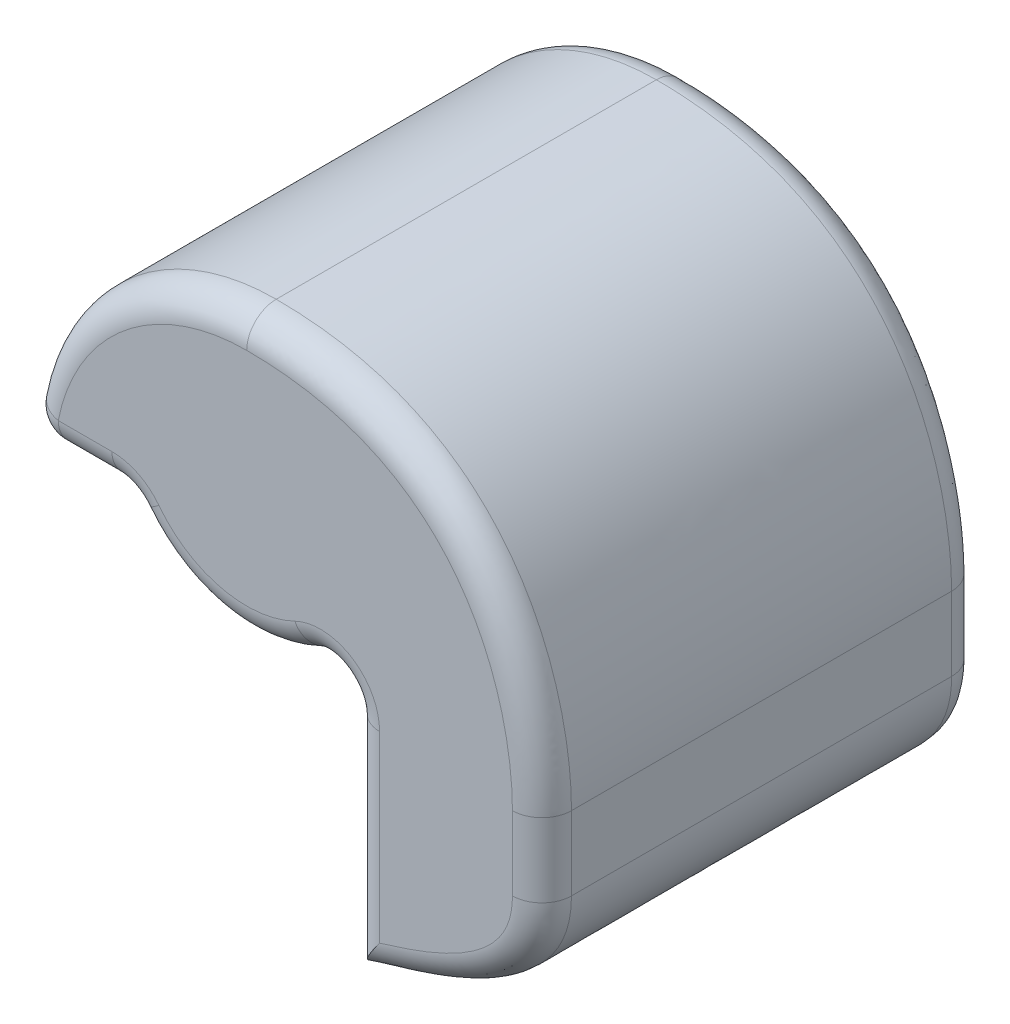
from build123d import *

# Parameters (mm, degrees)
SKETCH1_R            = 2
BOSS_EXTRUDE1_DEPTH  = 8.25
FILLET1_R            = 2
SKETCH1_3_R          = 2
BOSS_EXTRUDE2_DEPTH  = 13.25
FILLET1_OF_MIRROR1_R = 2
BOSS_EXTRUDE3_DEPTH  = 13.25
FILLET5_R            = 4
FILLET6_R            = 2


with BuildPart() as part:
    # Sketch1 → Boss-Extrude1 (new body)
    with BuildSketch(Plane.XY):
        with BuildLine():
            Line((7, -15.5), (7, -25.5))
            add(Edge.make_bspline(
                [(7, -25.5), (10.542331325, -24.196544486), (20, -22.646886742), (20, -15.5)],
                knots=[0, 0, 0, 0, 1, 1, 1, 1], degree=3))
            Line((20, -15.5), (20, -10.5))
            add(Edge.make_bspline(
                [(20, -10.5), (20, -3.471131344), (16.29951196, 9.5), (0, 9.5)],
                knots=[0, 0, 0, 0, 1, 1, 1, 1], degree=3))
            ThreePointArc((0, 9.5), (-10.431323023, 5.282403127), (-15, -5))
            Line((-15, -5), (-8.077747211, -5))
            ThreePointArc((-8.077747211, -5), (-0.892381106, -9.457994288), (7, -6.422616289))
            Line((7, -6.422616289), (7, -15.5))
        make_face()
        Circle(SKETCH1_R, mode=Mode.SUBTRACT)
        Circle(SKETCH1_R)
    boss_extrude1 = extrude(amount=BOSS_EXTRUDE1_DEPTH)

    # Fillet1
    fillet1_edges = [part.edges().sort_by_distance(p)[0] for p in [
        (7, -6.422616289, 4.125),
        (-8.077747211, -5, 4.125),
        (-15, -5, 4.125),
    ]]
    fillet(fillet1_edges, radius=FILLET1_R)

    # Sketch1_3 → Boss-Extrude2 (add)
    with BuildSketch(Plane.XY):
        Circle(SKETCH1_3_R)
    extrude(amount=-BOSS_EXTRUDE2_DEPTH)

    # Mirror1: Boss-Extrude1 across plane
    add(boss_extrude1.mirror(Plane(origin=(0, 0, -6.625), x_dir=(1, 0, 0), z_dir=(0, 0, -1))))

    # Fillet1 of Mirror1
    fillet1_of_mirror1_edges = [part.edges().sort_by_distance(p)[0] for p in [
        (7, -6.422616289, -17.375),
        (-8.077747211, -5, -17.375),
        (-15, -5, -17.375),
    ]]
    fillet(fillet1_of_mirror1_edges, radius=FILLET1_OF_MIRROR1_R)

    # Sketch2 → Boss-Extrude3 (add)
    with BuildSketch(Plane(origin=(0, 0, 0), x_dir=(-1, 0, 0), z_dir=(0, 0, -1))):
        with BuildLine():
            Line((-7, -25.5), (-7, -10.356157589))
            Line((-7, -10.356157589), (-7, -6.892055973))
            ThreePointArc((-7, -6.892055973), (-8.464101615, -8.356157589), (-9, -10.356157589))
            Line((-9, -10.356157589), (-9, -22.771805639))
            add(Edge.make_bspline(
                [(-18, -15.5), (-18, -15.755810099), (-17.96384044, -16.287511283), (-17.769644463, -17.176482985), (-17.326663811, -18.150730827), (-16.473613849, -19.194167826), (-14.905607021, -20.459045473), (-12.82414289, -21.481239618), (-10.597371428, -22.278497003), (-9.539012997, -22.607951452), (-9, -22.771805639)],
                knots=[0, 0, 0, 0, 0.050516154, 0.101032309, 0.202064618, 0.303096927, 0.404129236, 0.606193854, 0.707226163, 0.808258472, 0.808258472, 0.808258472, 0.808258472], degree=3))
            Line((-18, -15.5), (-18, -10.5))
            add(Edge.make_bspline(
                [(-6.962022671, 6.463763635), (-7.052846693, 6.433357714), (-7.813282932, 6.171704453), (-9.764374575, 5.337056232), (-12.300959997, 3.59990947), (-14.595833208, 1.024905795), (-16.245773011, -1.88869544), (-17.142002116, -4.439111746), (-17.608268155, -6.440579265), (-17.843029574, -7.893234579), (-17.952096873, -9.034515744), (-17.993489628, -9.897259581), (-18, -10.296370516), (-18, -10.5)],
                knots=[0.179104723, 0.179104723, 0.179104723, 0.179104723, 0.1875, 0.25, 0.375, 0.5, 0.625, 0.75, 0.8125, 0.875, 0.9375, 0.96875, 1, 1, 1, 1], degree=3))
            ThreePointArc((-6.962022671, 6.463763635), (-3.797646999, 8.707920376), (0, 9.5))
            add(Edge.make_bspline(
                [(0, 9.5), (-16.29951196, 9.5), (-20, -3.471131344), (-20, -10.5)],
                knots=[0, 0, 0, 0, 1, 1, 1, 1], degree=3))
            Line((-20, -10.5), (-20, -15.5))
            add(Edge.make_bspline(
                [(-20, -15.5), (-20, -22.646886742), (-10.542331325, -24.196544486), (-7, -25.5)],
                knots=[0, 0, 0, 0, 1, 1, 1, 1], degree=3))
        make_face()
        with BuildLine():
            ThreePointArc((-9, -10.356157589), (-8.464101615, -8.356157589), (-7, -6.892055973))
            Line((-7, -6.892055973), (-7, -6.422616289))
            ThreePointArc((-7, -6.422616289), (-9.499958745, 0.027997239), (-6.962022671, 6.463763635))
            add(Edge.make_bspline(
                [(-6.962022671, 6.463763635), (-7.052846693, 6.433357714), (-7.813282932, 6.171704453), (-9.764374575, 5.337056232), (-12.300959997, 3.59990947), (-14.595833208, 1.024905795), (-16.245773011, -1.88869544), (-17.142002116, -4.439111746), (-17.608268155, -6.440579265), (-17.843029574, -7.893234579), (-17.952096873, -9.034515744), (-17.993489628, -9.897259581), (-18, -10.296370516), (-18, -10.5)],
                knots=[0.179104723, 0.179104723, 0.179104723, 0.179104723, 0.1875, 0.25, 0.375, 0.5, 0.625, 0.75, 0.8125, 0.875, 0.9375, 0.96875, 1, 1, 1, 1], degree=3))
            Line((-18, -10.5), (-18, -15.5))
            add(Edge.make_bspline(
                [(-18, -15.5), (-18, -15.755810099), (-17.96384044, -16.287511283), (-17.769644463, -17.176482985), (-17.326663811, -18.150730827), (-16.473613849, -19.194167826), (-14.905607021, -20.459045473), (-12.82414289, -21.481239618), (-10.597371428, -22.278497003), (-9.539012997, -22.607951452), (-9, -22.771805639)],
                knots=[0, 0, 0, 0, 0.050516154, 0.101032309, 0.202064618, 0.303096927, 0.404129236, 0.606193854, 0.707226163, 0.808258472, 0.808258472, 0.808258472, 0.808258472], degree=3))
            Line((-9, -22.771805639), (-9, -10.356157589))
        make_face()
        with BuildLine():
            ThreePointArc((0, 9.5), (-3.797646999, 8.707920376), (-6.962022671, 6.463763635))
            add(Edge.make_bspline(
                [(0, 7.5), (-0.46330758, 7.5), (-1.408127817, 7.476315508), (-3.148637138, 7.339831525), (-5.045865316, 7.030251245), (-6.376692574, 6.659719511), (-6.962022671, 6.463763635)],
                knots=[0, 0, 0, 0, 0.03125, 0.0625, 0.125, 0.179104723, 0.179104723, 0.179104723, 0.179104723], degree=3))
            ThreePointArc((0, 7.5), (4.480264496, 6.704136669), (8.41232664, 4.413928013))
            ThreePointArc((8.41232664, 4.413928013), (4.915164488, 8.129646859), (0, 9.5))
        make_face()
        with BuildLine():
            ThreePointArc((10.756875796, 4.957912553), (5.83825606, 8.317928453), (0, 9.5))
            ThreePointArc((0, 9.5), (4.915164488, 8.129646859), (8.41232664, 4.413928013))
            ThreePointArc((8.41232664, 4.413928013), (8.878084444, 3.999472118), (9.323449498, 3.563176359))
            Line((9.323449498, 3.563176359), (10.756875796, 4.957912553))
        make_face()
    extrude(amount=BOSS_EXTRUDE3_DEPTH)

    # Fillet5
    fillet5_edges = [part.edges().sort_by_distance(p)[0] for p in [
        (6.962022671, 6.463763635, -6.625),
        (7, -6.422616289, -6.625),
    ]]
    fillet(fillet5_edges, radius=FILLET5_R)

    # Fillet6
    fillet6_edges = [part.edges().sort_by_distance(p)[0] for p in [
        (15.288594231, -22.445576253, 8.25),
        (20, -13, 8.25),
        (14.507114548, 4.059861745, 8.25),
        (-10.944293973, -5, 8.25),
        (-9.53465116, 6.082286189, 8.25),
        (7, -17.928078794, 8.25),
        (-2.196224683, -9.24265098, 8.25),
        (-14.30901072, -4.270556616, 8.25),
        (6.063219066, -8.662178481, 8.25),
        (-8.239492059, -5.206291187, 8.25),
        (14.507114548, 4.059861745, -21.5),
        (20, -13, -21.5),
        (15.288594231, -22.445576253, -21.5),
        (-9.53465116, 6.082286189, -21.5),
        (-10.944293973, -5, -21.5),
        (7, -17.928078794, -21.5),
        (-2.196224683, -9.24265098, -21.5),
        (-14.30901072, -4.270556616, -21.5),
        (6.063219066, -8.662178481, -21.5),
        (-8.239492059, -5.206291187, -21.5),
    ]]
    fillet(fillet6_edges, radius=FILLET6_R)


solid = part.part
